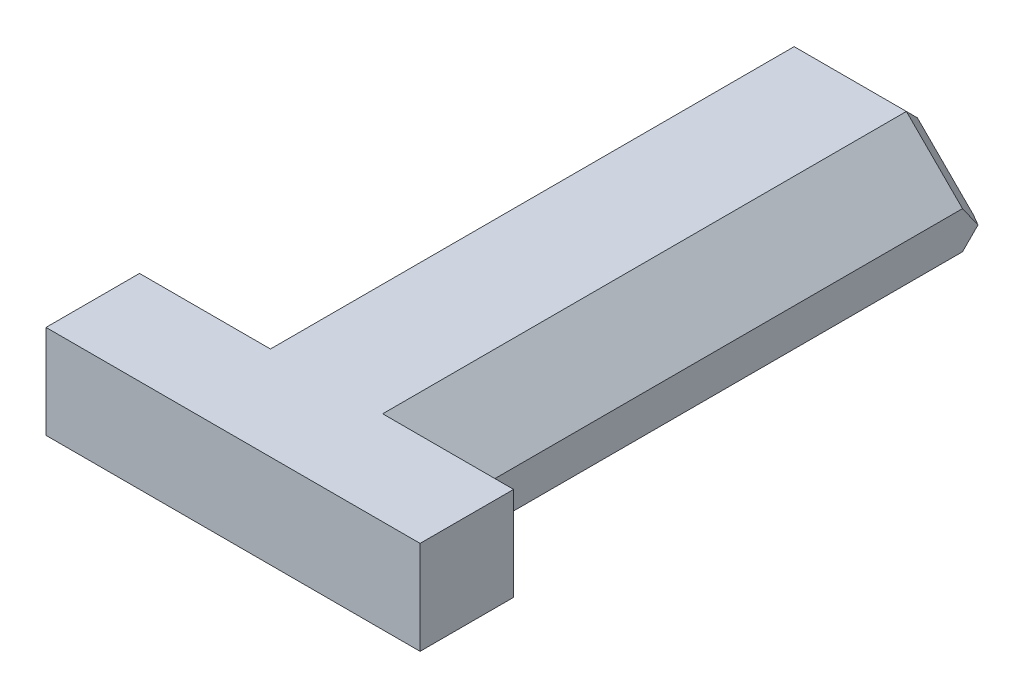
from build123d import *

# Parameters (mm, degrees)
EXTRUDE_1_DEPTH     = 29
EXTRUDE_2_DEPTH     = 5
CHAMFER_1_SIZE      = 1
SKETCH_4_W          = 2
SKETCH_4_H          = 3.10400654
SKETCH_4_H_2        = 3.326169865
CUT_EXTRUDE_1_DEPTH = 30


with BuildPart() as part:
    # 草图1 → 凸台-拉伸1 (new body)
    with BuildSketch(Plane.XY):
        Polygon((-19.832016219, -9.875726629), (-3.832016219, -9.875726629), (-8.832016219, -4.875726629), (-14.832016219, -4.875726629), align=None)
    extrude(amount=EXTRUDE_1_DEPTH)

    # 草图3 → 凸台-拉伸2 (add)
    with BuildSketch(Plane.XZ.offset(9.875726629)):
        Polygon((-11.832016219, 29), (-1.832016219, 29), (-1.832016219, 34), (-21.832016219, 34), (-21.832016219, 29), align=None)
    extrude(amount=-EXTRUDE_2_DEPTH)

    # 倒角1
    chamfer_1_edges = [part.edges().sort_by_distance(p)[0] for p in [
        (-11.832016219, -4.875726629, 0),
        (-6.332016219, -7.375726629, 0),
        (-11.832016219, -9.875726629, 0),
        (-17.332016219, -7.375726629, 0),
    ]]
    chamfer(chamfer_1_edges, length=CHAMFER_1_SIZE)

    # 草图4 → 切除-拉伸1 (cut, through all)
    with BuildSketch(Plane(origin=(0, 0, 29), x_dir=(-1, 0, 0), z_dir=(0, 0, -1))):
        with Locations((4.832016219, -8.323723359)):
            Rectangle(SKETCH_4_W, SKETCH_4_H)
        with Locations((18.832016219, -8.212641697)):
            Rectangle(SKETCH_4_W, SKETCH_4_H_2)
    extrude(amount=CUT_EXTRUDE_1_DEPTH, mode=Mode.SUBTRACT)


solid = part.part
